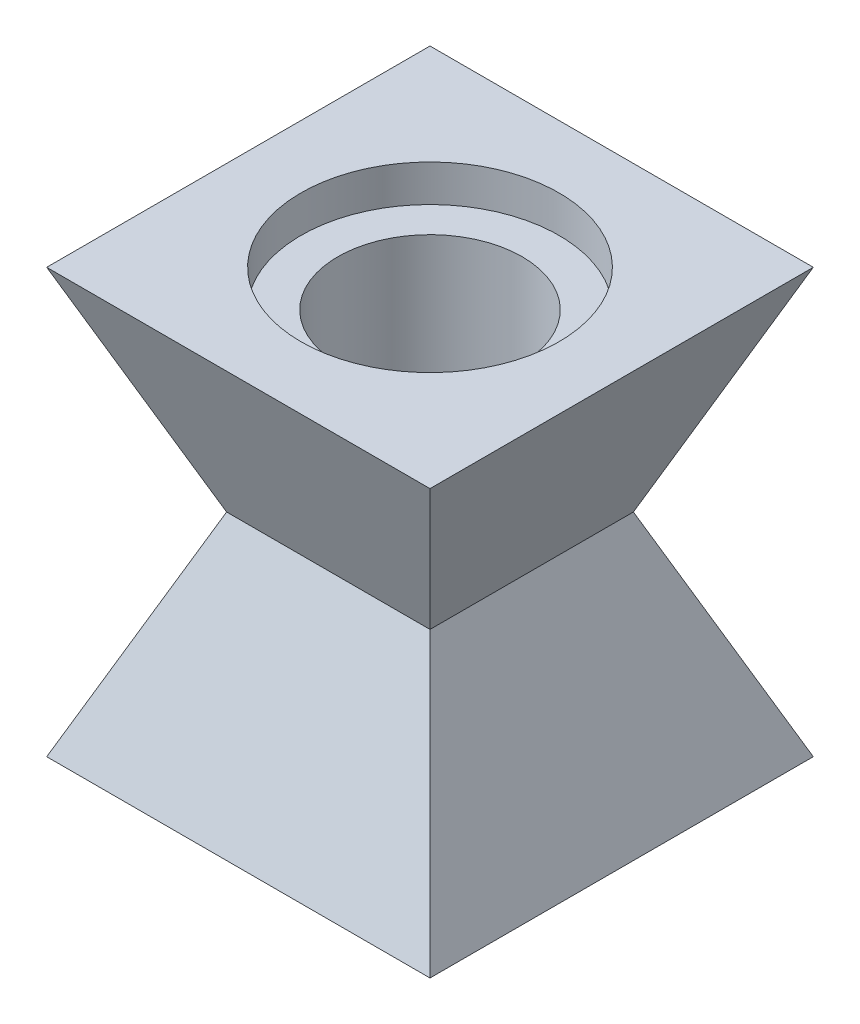
from build123d import *

# Parameters (mm, degrees)
SKETCH1_W           = 104
SKETCH1_H           = 104
BOSS_EXTRUDE1_DEPTH = 57.5
BOSS_EXTRUDE1_TAPER = 23
SKETCH1_3_R         = 25
CUT_EXTRUDE1_DEPTH  = 94.350147468
SKETCH3_R           = 35
CUT_EXTRUDE2_DEPTH  = 10


with BuildPart() as part:
    # Sketch1 → Boss-Extrude1 (new body)
    with BuildSketch(Plane(origin=(0, 0, 0), x_dir=(1, 0, 0), z_dir=(0, 1, 0))):
        Rectangle(SKETCH1_W, SKETCH1_H)
    boss_extrude1 = extrude(amount=-BOSS_EXTRUDE1_DEPTH, taper=BOSS_EXTRUDE1_TAPER)

    # Sketch1_3 → Cut-Extrude1 (cut, through all)
    with BuildSketch(Plane(origin=(0, 0, 0), x_dir=(1, 0, 0), z_dir=(0, 1, 0))):
        Circle(SKETCH1_3_R)
    cut_extrude1 = extrude(amount=-CUT_EXTRUDE1_DEPTH, mode=Mode.SUBTRACT)

    # Sketch3 → Cut-Extrude2 (cut)
    with BuildSketch(Plane(origin=(0, 0, 0), x_dir=(1, 0, 0), z_dir=(0, 1, 0))):
        Circle(SKETCH3_R)
    cut_extrude2 = extrude(amount=-CUT_EXTRUDE2_DEPTH, mode=Mode.SUBTRACT)

    # Mirror2: Boss-Extrude1, Cut-Extrude1, Cut-Extrude2 across plane
    add(boss_extrude1.mirror(Plane.ZX.offset(-57.5)))
    add(cut_extrude1.mirror(Plane.ZX.offset(-57.5)), mode=Mode.SUBTRACT)
    add(cut_extrude2.mirror(Plane.ZX.offset(-57.5)), mode=Mode.SUBTRACT)


solid = part.part
